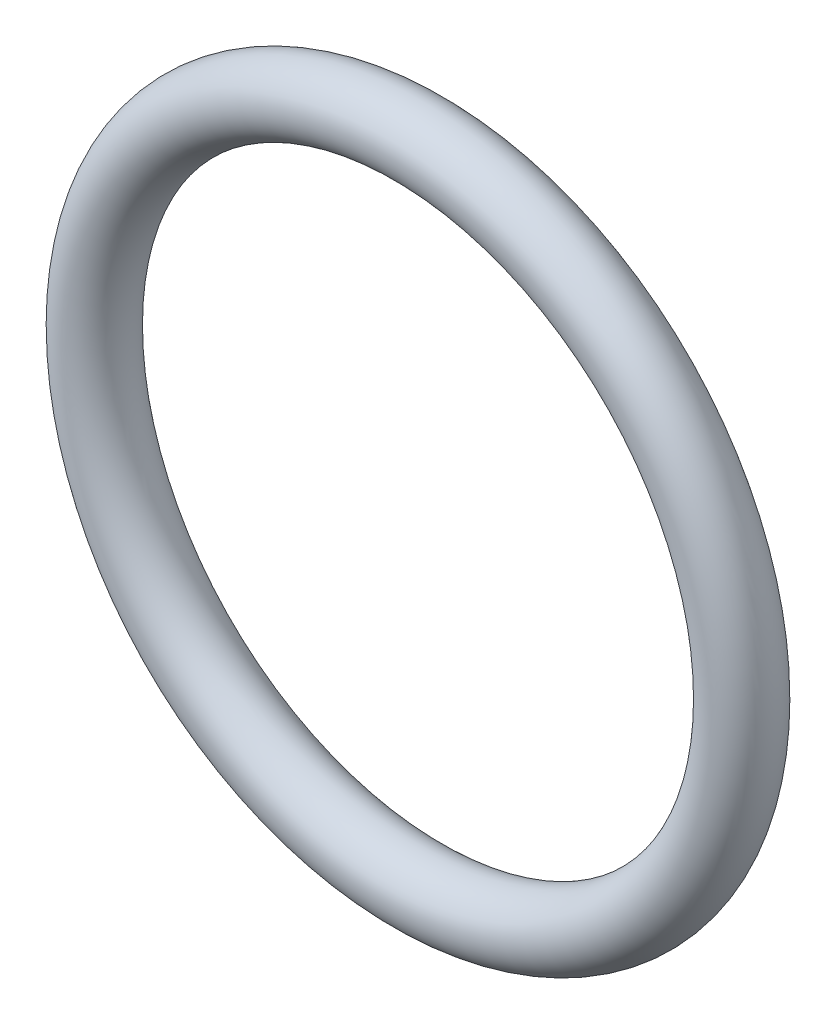
from build123d import *

# Parameters (mm, degrees)
SKETCH1_R = 0.5


with BuildPart() as part:
    # Sketch1 → Revolve1 (revolve)
    with BuildSketch(Plane(origin=(0, 0, 0), x_dir=(0, -1, 0), z_dir=(1, 0, 0))):
        with Locations((4.75, 0)):
            Circle(SKETCH1_R)
    revolve(axis=Axis((0, 0, 0.5), (0, 0, -1)))


solid = part.part
